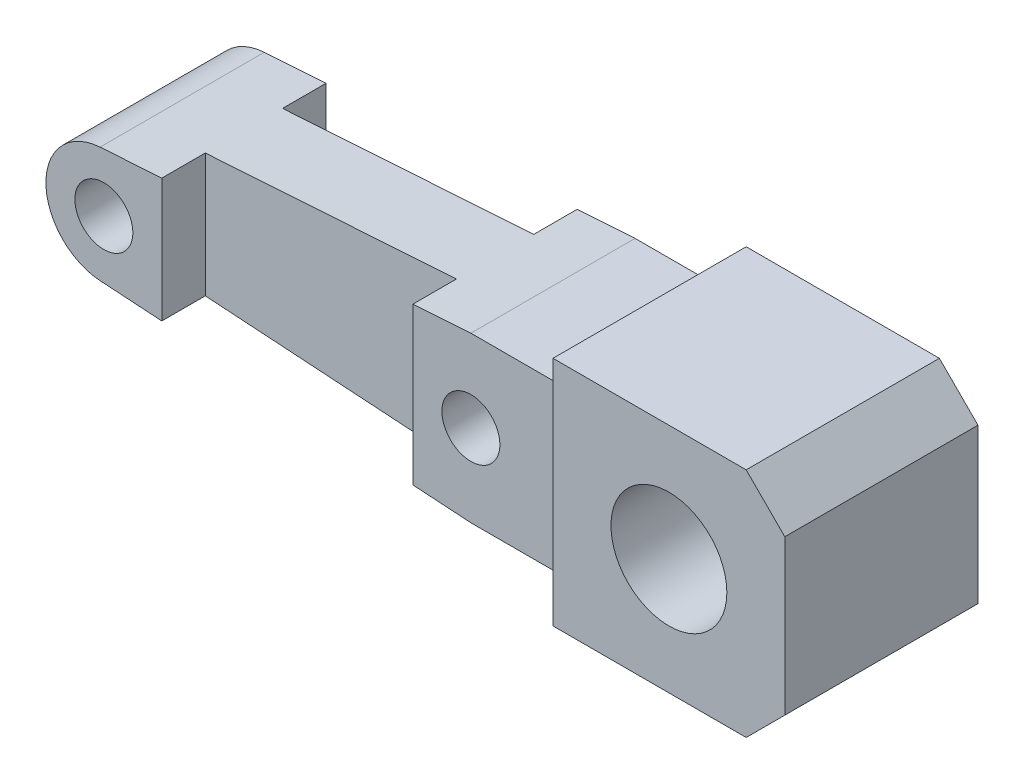
from build123d import *

# Parameters (mm, degrees)
ESQUISSE1_R             = 6
ESQUISSE1_R_2           = 3
BOSS_EXTRU_1_DEPTH      = 20
ESQUISSE3_W             = 16
ESQUISSE3_H             = 17
ESQUISSE3_W_2           = 24.161002882
ESQUISSE3_H_2           = 23.937604634
ENL_V_MAT_EXTRU_1_DEPTH = 1.5
ESQUISSE4_W             = 26
ESQUISSE4_H             = 16.214580426
ENL_V_MAT_EXTRU_2_DEPTH = 6


with BuildPart() as part:
    # Esquisse1 → Boss.-Extru.1 (new body)
    with BuildSketch(Plane.XY):
        Polygon((8, 12), (-12, 12), (-12, -12), (8, -12), (12, -8), (12, 8), align=None)
        Circle(ESQUISSE1_R, mode=Mode.SUBTRACT)
        with BuildLine():
            Line((-12, 8.5), (-22, 8.5))
            Line((-22, 8.5), (-60.391871312, 5.987189397))
            ThreePointArc((-60.391871312, 5.987189397), (-66, 0), (-60.391871312, -5.987189397))
            Line((-60.391871312, -5.987189397), (-22, -8.5))
            Line((-22, -8.5), (-12, -8.5))
            Line((-12, -8.5), (-12, 8.5))
        make_face()
        with Locations((-22, 0)):
            Circle(ESQUISSE1_R_2, mode=Mode.SUBTRACT)
        with Locations((-60, 0)):
            Circle(ESQUISSE1_R_2, mode=Mode.SUBTRACT)
    extrude(amount=BOSS_EXTRU_1_DEPTH)

    # Esquisse3 → Enlèv. mat.-Extru.1 (cut)
    with BuildSketch(Plane.XY.offset(20)):
        with Locations((-20, 0)):
            Rectangle(ESQUISSE3_W, ESQUISSE3_H)
        with Locations((-66.080501441, -0.730031796)):
            Rectangle(ESQUISSE3_W_2, ESQUISSE3_H_2)
    enl_v_mat_extru_1 = extrude(amount=-ENL_V_MAT_EXTRU_1_DEPTH, mode=Mode.SUBTRACT)

    # Esquisse4 → Enlèv. mat.-Extru.2 (cut)
    with BuildSketch(Plane.XY.offset(20)):
        with Locations((-41, 0)):
            Rectangle(ESQUISSE4_W, ESQUISSE4_H)
    enl_v_mat_extru_2 = extrude(amount=-ENL_V_MAT_EXTRU_2_DEPTH, mode=Mode.SUBTRACT)

    # Symétrie1: Enlèv. mat.-Extru.1, Enlèv. mat.-Extru.2 across plane
    add(enl_v_mat_extru_1.mirror(Plane.XY.offset(10)), mode=Mode.SUBTRACT)
    add(enl_v_mat_extru_2.mirror(Plane.XY.offset(10)), mode=Mode.SUBTRACT)


solid = part.part
